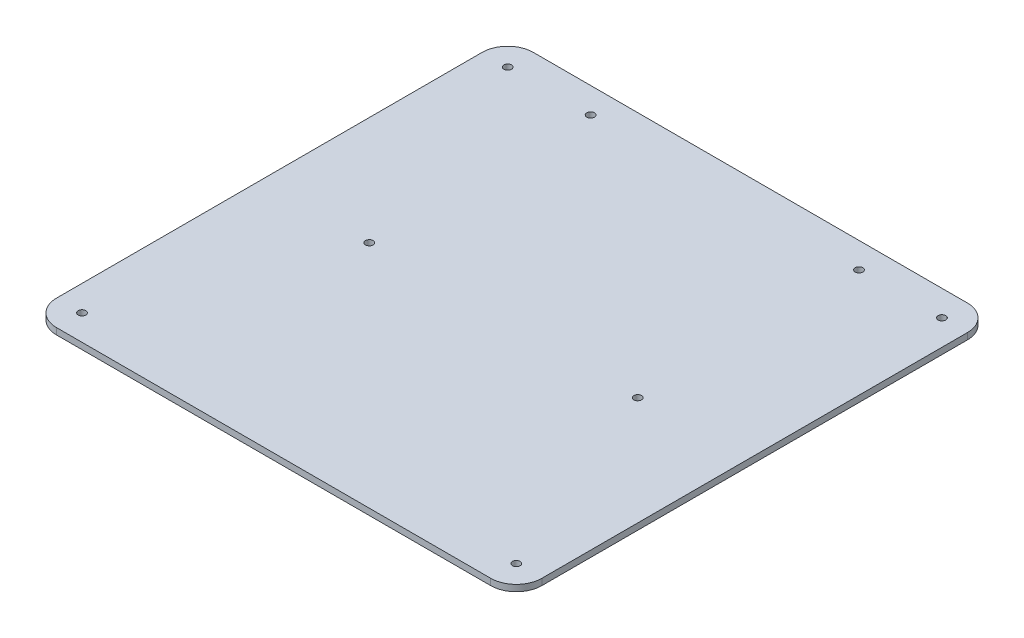
from build123d import *

# Parameters (mm, degrees)
SKETCH_1_R      = 1.5
EXTRUDE_1_DEPTH = 2.5


with BuildPart() as part:
    # 草图1 → 凸台-拉伸1 (new body)
    with BuildSketch(Plane(origin=(0, 67.13711373, 0), x_dir=(1, 0, 0), z_dir=(0, 1, 0))):
        with BuildLine():
            Line((1.900520775, 39.917702002), (-168.099479225, 39.917702002))
            ThreePointArc((-168.099479225, 39.917702002), (-175.170547037, 36.988769814), (-178.099479225, 29.917702002))
            Line((-178.099479225, 29.917702002), (-178.099479225, -136.727321584))
            ThreePointArc((-178.099479225, -136.727321584), (-175.170547037, -143.798389396), (-168.099479225, -146.727321584))
            Line((-168.099479225, -146.727321584), (1.900520775, -146.727321584))
            ThreePointArc((1.900520775, -146.727321584), (8.971588587, -143.798389396), (11.900520775, -136.727321584))
            Line((11.900520775, -136.727321584), (11.900520775, 29.917702002))
            ThreePointArc((11.900520775, 29.917702002), (8.971588587, 36.988769814), (1.900520775, 39.917702002))
        make_face()
        with Locations((-30.568515715, 29.917702002)):
            Circle(SKETCH_1_R, mode=Mode.SUBTRACT)
        with Locations((-135.630442735, 29.917702002)):
            Circle(SKETCH_1_R, mode=Mode.SUBTRACT)
        with Locations((-135.630442735, -56.727321584)):
            Circle(SKETCH_1_R, mode=Mode.SUBTRACT)
        with Locations((-30.568515715, -56.727321584)):
            Circle(SKETCH_1_R, mode=Mode.SUBTRACT)
        with Locations((1.900520775, 29.917702002)):
            Circle(SKETCH_1_R, mode=Mode.SUBTRACT)
        with Locations((1.900520775, -136.727321584)):
            Circle(SKETCH_1_R, mode=Mode.SUBTRACT)
        with Locations((-168.099479225, -136.727321584)):
            Circle(SKETCH_1_R, mode=Mode.SUBTRACT)
        with Locations((-168.099479225, 29.917702002)):
            Circle(SKETCH_1_R, mode=Mode.SUBTRACT)
    extrude(amount=EXTRUDE_1_DEPTH)


solid = part.part
